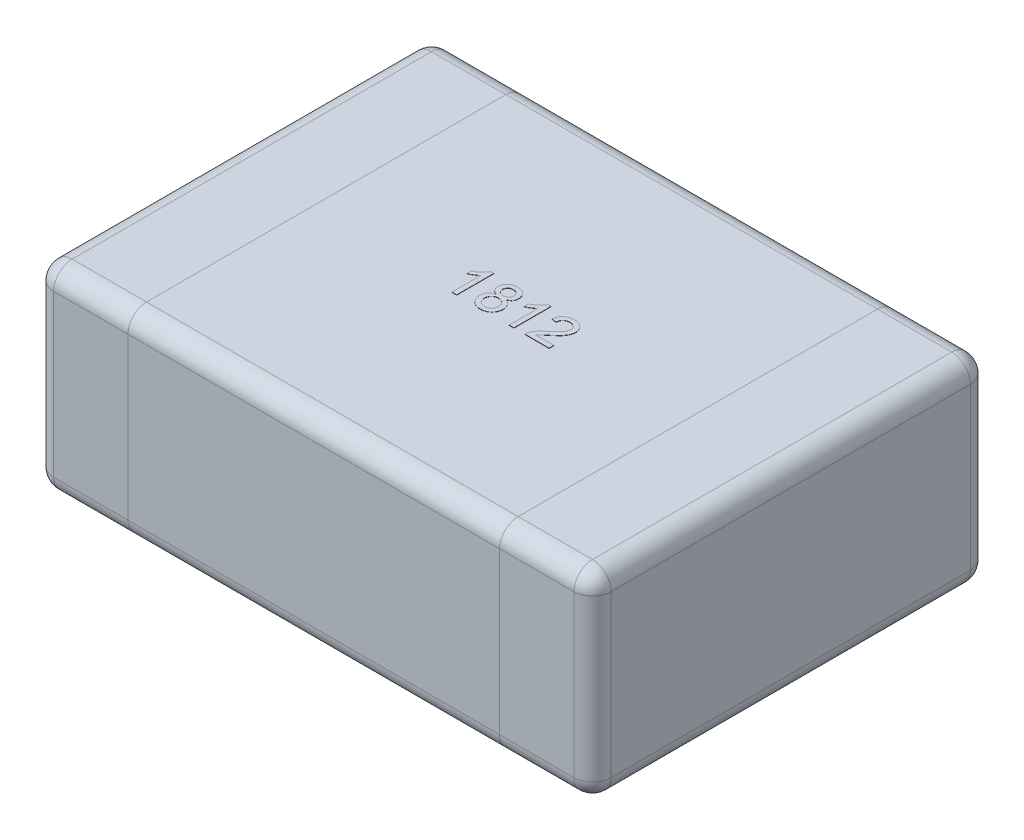
from build123d import *

# Parameters (mm, degrees)
SKETCH1_W      = 4.5
SKETCH1_H      = 3.2
EXTRUDE1_DEPTH = 1.6
FILLET1_R      = 0.15
EXTRUDE2_DEPTH = 0.002


with BuildPart() as part:
    # Sketch1 → Extrude1 (new body)
    with BuildSketch(Plane(origin=(0, 0, 0), x_dir=(1, 0, 0), z_dir=(0, 1, 0))):
        Rectangle(SKETCH1_W, SKETCH1_H)
    extrude(amount=EXTRUDE1_DEPTH)

    # Fillet1
    fillet1_edges = [part.edges().sort_by_distance(p)[0] for p in [
        (-2.25, 0.8, -1.6),
        (2.25, 0.8, -1.6),
        (0, 0, -1.6),
        (0, 1.6, -1.6),
        (2.25, 0.8, 1.6),
        (2.25, 0, 0),
        (2.25, 1.6, 0),
        (-2.25, 0.8, 1.6),
        (0, 0, 1.6),
        (0, 1.6, 1.6),
        (-2.25, 0, 0),
        (-2.25, 1.6, 0),
    ]]
    fillet(fillet1_edges, radius=FILLET1_R)

    # Sketch3 → Extrude2 (add)
    with BuildSketch(Plane(origin=(0, 1.6, 0), x_dir=(1, 0, 0), z_dir=(0, 1, 0))):
        with BuildLine():
            Line((-0.296153846, -0.15), (-0.334615385, -0.15))
            Line((-0.334615385, -0.15), (-0.334615385, 0.083774038))
            add(Edge.make_bspline(
                [(-0.334615385, 0.083774038), (-0.336830003, 0.081638311), (-0.341432846, 0.077199436), (-0.349213465, 0.070917319), (-0.35789763, 0.064550127), (-0.367372572, 0.05842736), (-0.377030672, 0.052663436), (-0.386363982, 0.047479672), (-0.39521668, 0.04309295), (-0.401047999, 0.040694273), (-0.403846154, 0.039543269)],
                knots=[0, 0, 0, 0, 9.226e-06, 1.9175e-05, 2.9969e-05, 4.1521e-05, 5.3002e-05, 6.3707e-05, 7.3544e-05, 8.2619e-05, 8.2619e-05, 8.2619e-05, 8.2619e-05], degree=3))
            Line((-0.403846154, 0.039543269), (-0.403846154, 0.075))
            add(Edge.make_bspline(
                [(-0.403846154, 0.075), (-0.399040034, 0.077475162), (-0.389567455, 0.082353558), (-0.37618475, 0.09077922), (-0.363690555, 0.099912985), (-0.352291699, 0.10975283), (-0.342073351, 0.119810917), (-0.333462201, 0.129959923), (-0.326256938, 0.139827828), (-0.322641922, 0.146709597), (-0.320913462, 0.15)],
                knots=[0, 0, 0, 0, 1.6212e-05, 3.1953e-05, 4.7386e-05, 6.26e-05, 7.7091e-05, 9.0349e-05, 0.000102505, 0.000113642, 0.000113642, 0.000113642, 0.000113642], degree=3))
            Line((-0.320913462, 0.15), (-0.296153846, 0.15))
            Line((-0.296153846, 0.15), (-0.296153846, -0.15))
        make_face()
        with BuildLine():
            add(Edge.make_bspline(
                [(-0.143028846, 0.014543269), (-0.146678167, 0.015970904), (-0.153675125, 0.018708154), (-0.163112218, 0.024186161), (-0.171099208, 0.030487887), (-0.177538027, 0.037765293), (-0.182445577, 0.045867936), (-0.185979208, 0.054692508), (-0.188048917, 0.06428817), (-0.188321315, 0.070923324), (-0.188461538, 0.074338942)],
                knots=[0, 0, 0, 0, 1.1742e-05, 2.2513e-05, 3.2603e-05, 4.214e-05, 5.1498e-05, 6.0884e-05, 7.0537e-05, 8.0779e-05, 8.0779e-05, 8.0779e-05, 8.0779e-05], degree=3))
            add(Edge.make_bspline(
                [(-0.188461538, 0.074338942), (-0.188395542, 0.07696711), (-0.188265988, 0.082126286), (-0.187146613, 0.089696504), (-0.185353774, 0.096950666), (-0.182809315, 0.103868299), (-0.179621525, 0.11050634), (-0.175599072, 0.11674318), (-0.170975512, 0.122755082), (-0.165559231, 0.128299027), (-0.159590583, 0.133376745), (-0.153125606, 0.137895415), (-0.146114829, 0.141590589), (-0.138675143, 0.144680065), (-0.130769761, 0.147098798), (-0.122370837, 0.148746091), (-0.113507979, 0.149793891), (-0.107434938, 0.149930227), (-0.104326923, 0.15)],
                knots=[0, 0, 0, 0, 7.881e-06, 1.547e-05, 2.2904e-05, 3.0261e-05, 3.7545e-05, 4.4948e-05, 5.2485e-05, 6.0262e-05, 6.8149e-05, 7.5968e-05, 8.3872e-05, 9.1874e-05, 0.000100106, 0.000108627, 0.00011752, 0.000126842, 0.000126842, 0.000126842, 0.000126842], degree=3))
            add(Edge.make_bspline(
                [(-0.104326923, 0.15), (-0.101199104, 0.149929518), (-0.095106464, 0.149792228), (-0.086196519, 0.148758507), (-0.077744593, 0.147025925), (-0.06975566, 0.144567827), (-0.062217127, 0.141425001), (-0.05517853, 0.137562056), (-0.048567409, 0.133042703), (-0.042552743, 0.127813048), (-0.037080114, 0.122135343), (-0.032338597, 0.1160526), (-0.02827195, 0.109706754), (-0.024911477, 0.103059254), (-0.022425386, 0.096034402), (-0.020530427, 0.088764549), (-0.019431263, 0.081163316), (-0.019298434, 0.076005089), (-0.019230769, 0.073377404)],
                knots=[0, 0, 0, 0, 9.382e-06, 1.8275e-05, 2.6867e-05, 3.5231e-05, 4.3312e-05, 5.1326e-05, 5.9277e-05, 6.7288e-05, 7.5194e-05, 8.29e-05, 9.0385e-05, 9.7776e-05, 0.00010519, 0.000112697, 0.000120286, 0.000128167, 0.000128167, 0.000128167, 0.000128167], degree=3))
            add(Edge.make_bspline(
                [(-0.019230769, 0.073377404), (-0.019340689, 0.070079507), (-0.019556221, 0.063612951), (-0.021752586, 0.054291357), (-0.025175809, 0.045589182), (-0.030123399, 0.037672273), (-0.036389338, 0.030458869), (-0.044164868, 0.024188177), (-0.053331905, 0.018718731), (-0.060152201, 0.015972556), (-0.063701923, 0.014543269)],
                knots=[0, 0, 0, 0, 9.878e-06, 1.9369e-05, 2.8564e-05, 3.782e-05, 4.7233e-05, 5.7098e-05, 6.7662e-05, 7.9128e-05, 7.9128e-05, 7.9128e-05, 7.9128e-05], degree=3))
            add(Edge.make_bspline(
                [(-0.063701923, 0.014543269), (-0.061462279, 0.013783016), (-0.057073548, 0.01229325), (-0.050869192, 0.009396685), (-0.045027977, 0.006273501), (-0.039516964, 0.002892652), (-0.034539578, -0.000997287), (-0.02992976, -0.00516632), (-0.02570689, -0.009673198), (-0.021928648, -0.014556251), (-0.018555448, -0.019712993), (-0.015667721, -0.025155995), (-0.01321523, -0.030807785), (-0.011119246, -0.036694571), (-0.009588296, -0.042857817), (-0.008517111, -0.049269202), (-0.007837474, -0.055894934), (-0.0077412, -0.060394987), (-0.007692308, -0.062680288)],
                knots=[0, 0, 0, 0, 7.091e-06, 1.3894e-05, 2.0509e-05, 2.6962e-05, 3.326e-05, 3.9429e-05, 4.5594e-05, 5.1761e-05, 5.7929e-05, 6.4058e-05, 7.0221e-05, 7.6399e-05, 8.2783e-05, 8.9244e-05, 9.5888e-05, 0.000102743, 0.000102743, 0.000102743, 0.000102743], degree=3))
            add(Edge.make_bspline(
                [(-0.007692308, -0.062680288), (-0.007768742, -0.065830053), (-0.007919323, -0.07203533), (-0.009242375, -0.081143948), (-0.011244211, -0.089894018), (-0.014163119, -0.098248578), (-0.017891291, -0.106213532), (-0.022503083, -0.113777315), (-0.027953185, -0.120932146), (-0.034080828, -0.127700265), (-0.040931529, -0.133818351), (-0.048342718, -0.139209736), (-0.056342204, -0.143725707), (-0.064832924, -0.147464915), (-0.073855537, -0.150362788), (-0.083398443, -0.152391913), (-0.093458467, -0.153600168), (-0.100337199, -0.15376306), (-0.103846154, -0.153846154)],
                knots=[0, 0, 0, 0, 9.444e-06, 1.8606e-05, 2.7557e-05, 3.6337e-05, 4.5101e-05, 5.3893e-05, 6.2859e-05, 7.2048e-05, 8.1241e-05, 9.0365e-05, 9.9489e-05, 0.000108745, 0.000118153, 0.000127865, 0.000137973, 0.000148498, 0.000148498, 0.000148498, 0.000148498], degree=3))
            add(Edge.make_bspline(
                [(-0.103846154, -0.153846154), (-0.107354757, -0.153761269), (-0.114232802, -0.153594866), (-0.124302017, -0.152411313), (-0.13383127, -0.150290202), (-0.142842151, -0.147389384), (-0.15138354, -0.143751415), (-0.159329302, -0.139133687), (-0.166788901, -0.133749133), (-0.173644365, -0.127593205), (-0.179822907, -0.120825808), (-0.185201165, -0.113565311), (-0.18978558, -0.105923451), (-0.193558454, -0.097857148), (-0.196434244, -0.089366329), (-0.198452508, -0.080482873), (-0.199777955, -0.071213566), (-0.199924942, -0.064888503), (-0.2, -0.061658654)],
                knots=[0, 0, 0, 0, 1.0525e-05, 2.0633e-05, 3.0358e-05, 3.9766e-05, 4.8998e-05, 5.8152e-05, 6.7276e-05, 7.6554e-05, 8.5742e-05, 9.4721e-05, 0.000103615, 0.000112434, 0.000121385, 0.000130452, 0.000139733, 0.000149418, 0.000149418, 0.000149418, 0.000149418], degree=3))
            add(Edge.make_bspline(
                [(-0.2, -0.061658654), (-0.199947829, -0.05925379), (-0.199845461, -0.054535032), (-0.199220126, -0.047613898), (-0.197973847, -0.04101733), (-0.19636856, -0.034706454), (-0.194330348, -0.028665483), (-0.191815826, -0.022941855), (-0.188765062, -0.017549405), (-0.185299194, -0.012453043), (-0.181374488, -0.007688549), (-0.177054552, -0.003297645), (-0.172323696, 0.000669723), (-0.16728823, 0.004329433), (-0.161737085, 0.007422605), (-0.155876706, 0.010261167), (-0.149606339, 0.012681934), (-0.145243302, 0.01391661), (-0.143028846, 0.014543269)],
                knots=[0, 0, 0, 0, 7.216e-06, 1.4158e-05, 2.0818e-05, 2.7333e-05, 3.3681e-05, 3.9923e-05, 4.6058e-05, 5.2242e-05, 5.839e-05, 6.4552e-05, 7.0692e-05, 7.6896e-05, 8.3194e-05, 8.9726e-05, 9.6422e-05, 0.000103324, 0.000103324, 0.000103324, 0.000103324], degree=3))
        make_face()
        with BuildLine():
            add(Edge.make_bspline(
                [(-0.15, 0.074158654), (-0.149885847, 0.071096846), (-0.149665252, 0.065180074), (-0.147266257, 0.056775734), (-0.143514926, 0.049226279), (-0.139117148, 0.043751589), (-0.134900784, 0.0400214), (-0.131381647, 0.037530885), (-0.127535911, 0.035416488), (-0.123335716, 0.033773046), (-0.11888279, 0.032317058), (-0.114023557, 0.031503267), (-0.108872232, 0.030841703), (-0.105311001, 0.03079379), (-0.103485577, 0.030769231)],
                knots=[0, 0, 0, 0, 9.163e-06, 1.7707e-05, 2.5985e-05, 3.4319e-05, 3.8576e-05, 4.2845e-05, 4.7228e-05, 5.1704e-05, 5.6361e-05, 6.1252e-05, 6.6455e-05, 7.1927e-05, 7.1927e-05, 7.1927e-05, 7.1927e-05], degree=3))
            add(Edge.make_bspline(
                [(-0.103485577, 0.030769231), (-0.101700447, 0.030794697), (-0.098219542, 0.030844356), (-0.093184237, 0.031492433), (-0.088425891, 0.032358), (-0.08401482, 0.033669634), (-0.079900096, 0.035375141), (-0.076148645, 0.037477611), (-0.072648204, 0.039893951), (-0.068555701, 0.043652639), (-0.064163992, 0.048935583), (-0.060400089, 0.056147793), (-0.058054585, 0.064038379), (-0.057815187, 0.069534632), (-0.057692308, 0.072355769)],
                knots=[0, 0, 0, 0, 5.352e-06, 1.0435e-05, 1.5209e-05, 1.9848e-05, 2.4212e-05, 2.8543e-05, 3.2728e-05, 3.694e-05, 4.5181e-05, 5.3192e-05, 6.1199e-05, 6.9644e-05, 6.9644e-05, 6.9644e-05, 6.9644e-05], degree=3))
            add(Edge.make_bspline(
                [(-0.057692308, 0.072355769), (-0.05784036, 0.075275526), (-0.05813006, 0.080988733), (-0.060469834, 0.089190299), (-0.06440905, 0.096618469), (-0.068909058, 0.102043156), (-0.073073957, 0.105973023), (-0.076637241, 0.108474646), (-0.080467784, 0.110603749), (-0.084580166, 0.112342448), (-0.088980333, 0.113744726), (-0.093680205, 0.114664689), (-0.098660033, 0.115309891), (-0.102081073, 0.115359183), (-0.103846154, 0.115384615)],
                knots=[0, 0, 0, 0, 8.749e-06, 1.7119e-05, 2.5345e-05, 3.3802e-05, 3.814e-05, 4.2492e-05, 4.6823e-05, 5.1266e-05, 5.5866e-05, 6.0651e-05, 6.5615e-05, 7.0907e-05, 7.0907e-05, 7.0907e-05, 7.0907e-05], degree=3))
            add(Edge.make_bspline(
                [(-0.103846154, 0.115384615), (-0.105611431, 0.115360006), (-0.109052754, 0.11531203), (-0.114065054, 0.114647467), (-0.118809467, 0.113812789), (-0.123242222, 0.112473285), (-0.127344894, 0.110722865), (-0.131160335, 0.108592567), (-0.134716868, 0.106154844), (-0.138911028, 0.102400216), (-0.14330372, 0.097117152), (-0.147173559, 0.09002013), (-0.149565244, 0.08228198), (-0.149853286, 0.076899968), (-0.15, 0.074158654)],
                knots=[0, 0, 0, 0, 5.292e-06, 1.0316e-05, 1.5148e-05, 1.973e-05, 2.4173e-05, 2.8504e-05, 3.2821e-05, 3.7078e-05, 4.5358e-05, 5.3291e-05, 6.12e-05, 6.941e-05, 6.941e-05, 6.941e-05, 6.941e-05], degree=3))
        make_face(mode=Mode.SUBTRACT)
        with BuildLine():
            add(Edge.make_bspline(
                [(-0.161538462, -0.0609375), (-0.161471953, -0.063405403), (-0.16133876, -0.06834771), (-0.160170375, -0.075688083), (-0.158187867, -0.082891764), (-0.155646938, -0.089965559), (-0.1520628, -0.096623957), (-0.147309829, -0.102567066), (-0.141345741, -0.107563675), (-0.134534427, -0.111784999), (-0.127101532, -0.115107544), (-0.119356237, -0.117426794), (-0.111498446, -0.118959238), (-0.106196901, -0.119140248), (-0.103545673, -0.119230769)],
                knots=[0, 0, 0, 0, 7.401e-06, 1.4821e-05, 2.2226e-05, 2.9795e-05, 3.7325e-05, 4.4805e-05, 5.2477e-05, 6.0548e-05, 6.8779e-05, 7.6821e-05, 8.4765e-05, 9.2713e-05, 9.2713e-05, 9.2713e-05, 9.2713e-05], degree=3))
            add(Edge.make_bspline(
                [(-0.103545673, -0.119230769), (-0.10135945, -0.119193736), (-0.097112242, -0.119121792), (-0.090921142, -0.11829967), (-0.085087726, -0.117052243), (-0.079585269, -0.115341816), (-0.074494761, -0.113001839), (-0.069733304, -0.110266914), (-0.065349603, -0.106961547), (-0.061344897, -0.10318929), (-0.057759976, -0.099016466), (-0.054689038, -0.094514901), (-0.052010223, -0.08981119), (-0.049823092, -0.08480382), (-0.048241444, -0.079482465), (-0.04702098, -0.073943134), (-0.046284709, -0.068128692), (-0.046198099, -0.064164781), (-0.046153846, -0.062139423)],
                knots=[0, 0, 0, 0, 6.555e-06, 1.2734e-05, 1.8699e-05, 2.4438e-05, 2.9979e-05, 3.5473e-05, 4.0881e-05, 4.6408e-05, 5.1949e-05, 5.735e-05, 6.2732e-05, 6.8169e-05, 7.37e-05, 7.9358e-05, 8.5173e-05, 9.1247e-05, 9.1247e-05, 9.1247e-05, 9.1247e-05], degree=3))
            add(Edge.make_bspline(
                [(-0.046153846, -0.062139423), (-0.046199509, -0.06007431), (-0.046288909, -0.056031148), (-0.047006468, -0.050089091), (-0.048295369, -0.044452304), (-0.0499529, -0.039035631), (-0.052199329, -0.033933308), (-0.054895853, -0.029072172), (-0.058197999, -0.024580352), (-0.061819065, -0.020305352), (-0.0659169, -0.016435488), (-0.070442192, -0.013098358), (-0.075251524, -0.010151107), (-0.080490384, -0.007890317), (-0.086043352, -0.006079372), (-0.09193681, -0.004763512), (-0.098194786, -0.003959162), (-0.102481472, -0.003884551), (-0.1046875, -0.003846154)],
                knots=[0, 0, 0, 0, 6.195e-06, 1.2128e-05, 1.7916e-05, 2.3523e-05, 2.9094e-05, 3.4611e-05, 4.0164e-05, 4.579e-05, 5.1402e-05, 5.7027e-05, 6.2633e-05, 6.8284e-05, 7.4099e-05, 8.0135e-05, 8.6374e-05, 9.2989e-05, 9.2989e-05, 9.2989e-05, 9.2989e-05], degree=3))
            add(Edge.make_bspline(
                [(-0.1046875, -0.003846154), (-0.106833622, -0.003884933), (-0.11104069, -0.003960952), (-0.117152397, -0.004769858), (-0.122938306, -0.00601207), (-0.128347512, -0.007830212), (-0.133447646, -0.010102166), (-0.13814543, -0.012958985), (-0.142524672, -0.016274938), (-0.1464516, -0.020129101), (-0.149994708, -0.02431577), (-0.153058103, -0.028803867), (-0.155764303, -0.033489281), (-0.157817981, -0.038525757), (-0.159556235, -0.043750476), (-0.160642919, -0.049264843), (-0.161415415, -0.055006205), (-0.161496847, -0.058931505), (-0.161538462, -0.0609375)],
                knots=[0, 0, 0, 0, 6.435e-06, 1.2614e-05, 1.8461e-05, 2.4162e-05, 2.9703e-05, 3.5176e-05, 4.0621e-05, 4.6146e-05, 5.1647e-05, 5.7048e-05, 6.243e-05, 6.7843e-05, 7.3336e-05, 7.8923e-05, 8.4677e-05, 9.0691e-05, 9.0691e-05, 9.0691e-05, 9.0691e-05], degree=3))
        make_face(mode=Mode.SUBTRACT)
        with BuildLine():
            Line((0.165384615, -0.15), (0.126923077, -0.15))
            Line((0.126923077, -0.15), (0.126923077, 0.083774038))
            add(Edge.make_bspline(
                [(0.126923077, 0.083774038), (0.124708458, 0.081638311), (0.120105616, 0.077199436), (0.112324997, 0.070917319), (0.103640832, 0.064550127), (0.09416589, 0.05842736), (0.08450779, 0.052663436), (0.075174479, 0.047479672), (0.066321782, 0.04309295), (0.060490463, 0.040694273), (0.057692308, 0.039543269)],
                knots=[0, 0, 0, 0, 9.226e-06, 1.9175e-05, 2.9969e-05, 4.1521e-05, 5.3002e-05, 6.3707e-05, 7.3544e-05, 8.2619e-05, 8.2619e-05, 8.2619e-05, 8.2619e-05], degree=3))
            Line((0.057692308, 0.039543269), (0.057692308, 0.075))
            add(Edge.make_bspline(
                [(0.057692308, 0.075), (0.062498428, 0.077475162), (0.071971006, 0.082353558), (0.085353711, 0.09077922), (0.097847906, 0.099912985), (0.109246762, 0.10975283), (0.11946511, 0.119810917), (0.128076261, 0.129959923), (0.135281523, 0.139827828), (0.13889654, 0.146709597), (0.140625, 0.15)],
                knots=[0, 0, 0, 0, 1.6212e-05, 3.1953e-05, 4.7386e-05, 6.26e-05, 7.7091e-05, 9.0349e-05, 0.000102505, 0.000113642, 0.000113642, 0.000113642, 0.000113642], degree=3))
            Line((0.140625, 0.15), (0.165384615, 0.15))
            Line((0.165384615, 0.15), (0.165384615, -0.15))
        make_face()
        with BuildLine():
            Line((0.45, -0.111538462), (0.45, -0.15))
            Line((0.45, -0.15), (0.253846154, -0.15))
            add(Edge.make_bspline(
                [(0.253846154, -0.15), (0.253842138, -0.147714123), (0.25383412, -0.14315003), (0.254606438, -0.136400026), (0.255816043, -0.129739566), (0.257183742, -0.125468478), (0.257872596, -0.123317308)],
                knots=[0, 0, 0, 0, 6.852e-06, 1.3681e-05, 2.0352e-05, 2.7121e-05, 2.7121e-05, 2.7121e-05, 2.7121e-05], degree=3))
            add(Edge.make_bspline(
                [(0.257872596, -0.123317308), (0.259145369, -0.119802551), (0.261736944, -0.112645929), (0.266987502, -0.102319922), (0.273163399, -0.092056365), (0.279176504, -0.08370038), (0.284683209, -0.077024532), (0.2893013, -0.071801454), (0.294418991, -0.066455018), (0.300032183, -0.060986201), (0.306086854, -0.055359583), (0.312591265, -0.049556401), (0.319622223, -0.043684801), (0.324530567, -0.039792861), (0.327043269, -0.037800481)],
                knots=[0, 0, 0, 0, 1.1205e-05, 2.2816e-05, 3.4678e-05, 4.712e-05, 5.3653e-05, 6.0635e-05, 6.8031e-05, 7.5851e-05, 8.4142e-05, 9.2826e-05, 0.000101998, 0.000111618, 0.000111618, 0.000111618, 0.000111618], degree=3))
            add(Edge.make_bspline(
                [(0.327043269, -0.037800481), (0.330903401, -0.034551471), (0.33833633, -0.028295295), (0.348832789, -0.019011711), (0.358419597, -0.010391377), (0.366944093, -0.002283205), (0.374476, 0.005234162), (0.381033001, 0.012143692), (0.386671516, 0.018423822), (0.391322709, 0.024301865), (0.395247064, 0.029852373), (0.398572608, 0.035266551), (0.401344007, 0.040638972), (0.403652212, 0.045952637), (0.405477806, 0.05123027), (0.406722208, 0.056487246), (0.407566119, 0.061671403), (0.407650553, 0.065120999), (0.407692308, 0.066826923)],
                knots=[0, 0, 0, 0, 1.5136e-05, 2.9145e-05, 4.2036e-05, 5.3811e-05, 6.4435e-05, 7.3957e-05, 8.2386e-05, 8.9745e-05, 9.643e-05, 0.000102769, 0.00010879, 0.00011455, 0.000120137, 0.000125516, 0.000130743, 0.000135857, 0.000135857, 0.000135857, 0.000135857], degree=3))
            add(Edge.make_bspline(
                [(0.407692308, 0.066826923), (0.407650548, 0.068512943), (0.407568617, 0.071820821), (0.406791261, 0.076661881), (0.405709119, 0.081323937), (0.403959625, 0.085723063), (0.4018772, 0.089989532), (0.399205988, 0.093988532), (0.396115944, 0.097819726), (0.392578106, 0.101382104), (0.388713958, 0.104724183), (0.384396323, 0.107502263), (0.379908783, 0.110003363), (0.375096521, 0.11201439), (0.369967356, 0.113491124), (0.364558627, 0.114562852), (0.358871192, 0.115242385), (0.354989917, 0.115336486), (0.353004808, 0.115384615)],
                knots=[0, 0, 0, 0, 5.054e-06, 9.915e-06, 1.4681e-05, 1.938e-05, 2.4083e-05, 2.89e-05, 3.3772e-05, 3.8829e-05, 4.3946e-05, 4.9063e-05, 5.4199e-05, 5.9345e-05, 6.4669e-05, 7.0185e-05, 7.5872e-05, 8.1827e-05, 8.1827e-05, 8.1827e-05, 8.1827e-05], degree=3))
            add(Edge.make_bspline(
                [(0.353004808, 0.115384615), (0.350919506, 0.115336725), (0.346838417, 0.115242999), (0.340872957, 0.114560756), (0.335209788, 0.113518381), (0.329862425, 0.111924678), (0.324837377, 0.109917004), (0.320155111, 0.107389877), (0.315740643, 0.104537208), (0.311733002, 0.101159863), (0.308108946, 0.097415076), (0.304891627, 0.093338135), (0.302255517, 0.088850365), (0.30007851, 0.084050442), (0.298328013, 0.078923275), (0.297057212, 0.07342967), (0.296364363, 0.067585487), (0.296225037, 0.063583392), (0.296153846, 0.061538462)],
                knots=[0, 0, 0, 0, 6.255e-06, 1.2241e-05, 1.7992e-05, 2.3507e-05, 2.8953e-05, 3.4195e-05, 3.9446e-05, 4.4693e-05, 4.9878e-05, 5.506e-05, 6.0233e-05, 6.5451e-05, 7.0848e-05, 7.6461e-05, 8.2334e-05, 8.8471e-05, 8.8471e-05, 8.8471e-05, 8.8471e-05], degree=3))
            Line((0.296153846, 0.061538462), (0.257692308, 0.065384615))
            add(Edge.make_bspline(
                [(0.257692308, 0.065384615), (0.258085824, 0.068736632), (0.258851376, 0.075257693), (0.260758261, 0.084702351), (0.263435355, 0.09348859), (0.266638724, 0.101738909), (0.27065445, 0.109312863), (0.275193881, 0.11636711), (0.280547932, 0.122677919), (0.286462737, 0.128444216), (0.293003099, 0.133525841), (0.300107584, 0.137965346), (0.30777294, 0.141678718), (0.315956474, 0.144753235), (0.324676973, 0.147085948), (0.333922102, 0.148758724), (0.343706727, 0.149789842), (0.350418121, 0.149928948), (0.353846154, 0.15)],
                knots=[0, 0, 0, 0, 1.0123e-05, 1.9693e-05, 2.8857e-05, 3.7651e-05, 4.6199e-05, 5.4533e-05, 6.2766e-05, 7.0968e-05, 7.9275e-05, 8.7563e-05, 9.6056e-05, 0.000104785, 0.00011375, 0.000123098, 0.000132946, 0.000143229, 0.000143229, 0.000143229, 0.000143229], degree=3))
            add(Edge.make_bspline(
                [(0.353846154, 0.15), (0.357315219, 0.149940596), (0.364072977, 0.149824877), (0.373920118, 0.14864084), (0.383211167, 0.146796713), (0.391980186, 0.144226564), (0.400175366, 0.140856333), (0.40780301, 0.136738671), (0.414898289, 0.131913745), (0.421342655, 0.126323636), (0.427153708, 0.120221095), (0.432246239, 0.113708369), (0.43650384, 0.106813279), (0.440128923, 0.09962981), (0.44281778, 0.092006182), (0.444708635, 0.084046037), (0.445993525, 0.075742575), (0.446099695, 0.070077103), (0.446153846, 0.0671875)],
                knots=[0, 0, 0, 0, 1.0403e-05, 2.0265e-05, 2.9705e-05, 3.8794e-05, 4.7633e-05, 5.6238e-05, 6.4755e-05, 7.3321e-05, 8.178e-05, 9.0002e-05, 9.8073e-05, 0.000106055, 0.000114096, 0.000122258, 0.000130579, 0.00013924, 0.00013924, 0.00013924, 0.00013924], degree=3))
            add(Edge.make_bspline(
                [(0.446153846, 0.0671875), (0.446071159, 0.06421876), (0.445905602, 0.058274728), (0.444613405, 0.049390154), (0.442402443, 0.040601997), (0.439471297, 0.0318033), (0.435466741, 0.022959142), (0.430407665, 0.013947517), (0.424131328, 0.004735138), (0.418095252, -0.003096409), (0.412476645, -0.009661219), (0.40749628, -0.015064442), (0.401734287, -0.020805005), (0.395406818, -0.027081717), (0.38825581, -0.033671804), (0.380486728, -0.040772611), (0.371929502, -0.048197271), (0.36598912, -0.053269443), (0.362920673, -0.055889423)],
                knots=[0, 0, 0, 0, 8.904e-06, 1.7828e-05, 2.6865e-05, 3.6063e-05, 4.5612e-05, 5.5944e-05, 6.7028e-05, 7.9024e-05, 8.5588e-05, 9.2946e-05, 0.000101063, 0.000109987, 0.000119681, 0.000130232, 0.000141562, 0.000153666, 0.000153666, 0.000153666, 0.000153666], degree=3))
            add(Edge.make_bspline(
                [(0.362920673, -0.055889423), (0.360293012, -0.058028619), (0.355282467, -0.062107737), (0.348153996, -0.068021343), (0.341769055, -0.07344396), (0.335978331, -0.078198712), (0.33099272, -0.08251558), (0.326636611, -0.086205504), (0.323068263, -0.089454013), (0.317634301, -0.094388563), (0.310751724, -0.101422266), (0.305680348, -0.108256719), (0.303245192, -0.111538462)],
                knots=[0, 0, 0, 0, 1.0165e-05, 1.9383e-05, 2.7786e-05, 3.5295e-05, 4.1859e-05, 4.7569e-05, 5.242e-05, 5.6334e-05, 6.9594e-05, 8.1844e-05, 8.1844e-05, 8.1844e-05, 8.1844e-05], degree=3))
            Line((0.303245192, -0.111538462), (0.45, -0.111538462))
        make_face()
    extrude(amount=EXTRUDE2_DEPTH)


solid = part.part
